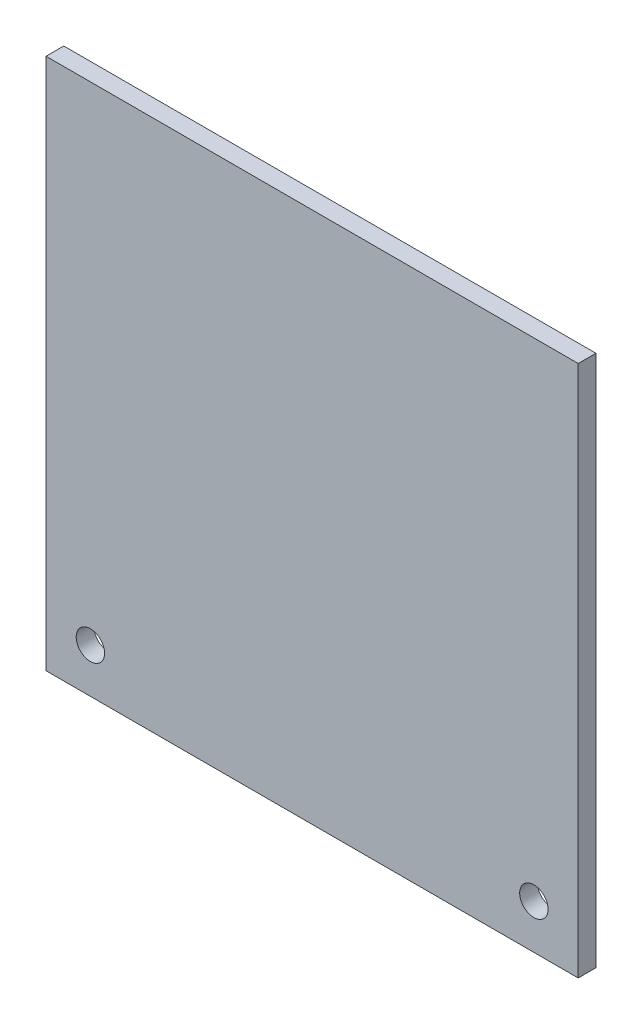
from build123d import *

# Parameters (mm, degrees)
SKETCH1_W                = 60
SKETCH1_H                = 60
BOSS_EXTRUDE1_DEPTH      = 2
M3_CLEARANCE_HOLE1_D     = 3.2
M3_CLEARANCE_HOLE1_DEPTH = 2


with BuildPart() as part:
    # Sketch1 → Boss-Extrude1 (new body)
    with BuildSketch(Plane.XY):
        with Locations((30, 30)):
            Rectangle(SKETCH1_W, SKETCH1_H)
    extrude(amount=BOSS_EXTRUDE1_DEPTH)

    # M3 Clearance Hole1
    with Locations(Plane(origin=(0, 0, 0), x_dir=(-1, 0, 0), z_dir=(0, 0, -1))):
        with Locations((-55, 5), (-5, 5)):
            Hole(M3_CLEARANCE_HOLE1_D / 2, depth=M3_CLEARANCE_HOLE1_DEPTH)


solid = part.part
